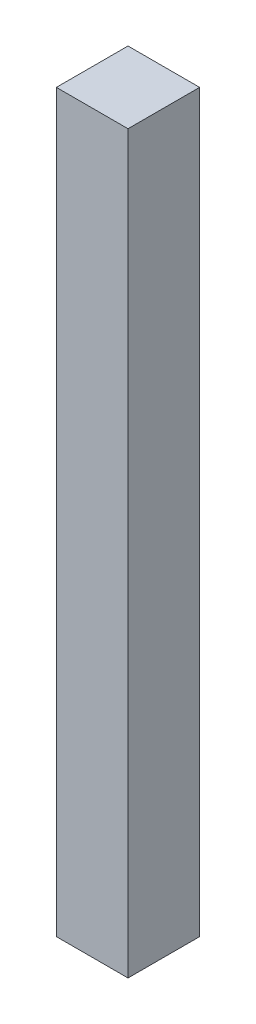
from build123d import *

# Parameters (mm, degrees)
SKETCH1_W           = 25.4
SKETCH1_H           = 25.4
BOSS_EXTRUDE1_DEPTH = 260.8


with BuildPart() as part:
    # Sketch1 → Boss-Extrude1 (new body)
    with BuildSketch(Plane(origin=(0, 0, 0), x_dir=(1, 0, 0), z_dir=(0, 1, 0))):
        with Locations((-27.135508984, 5.913615805)):
            Rectangle(SKETCH1_W, SKETCH1_H)
    extrude(amount=BOSS_EXTRUDE1_DEPTH)


solid = part.part
